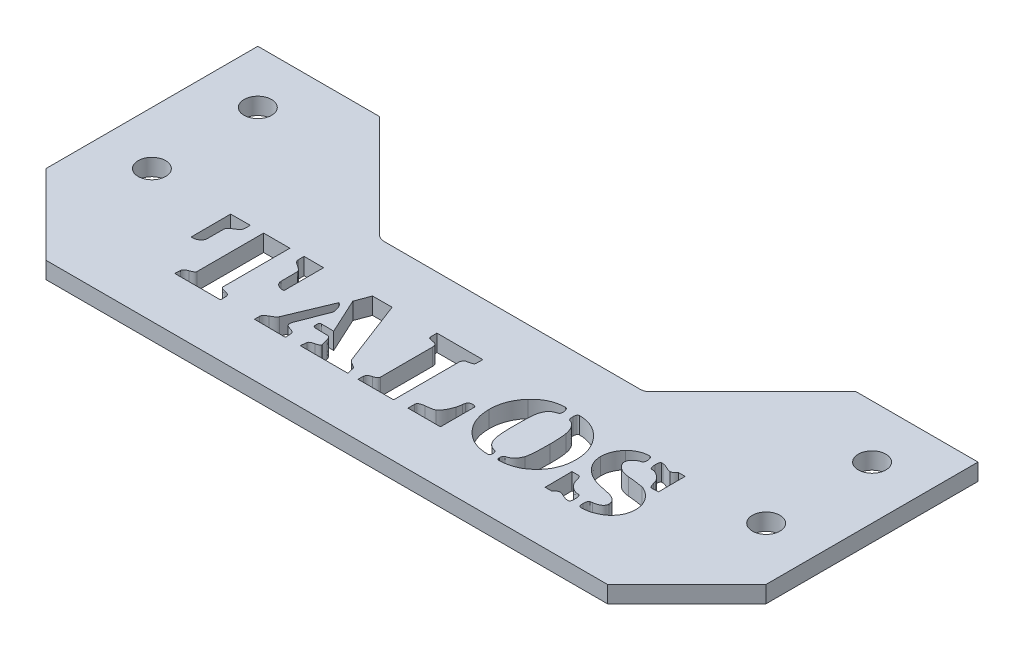
from build123d import *

# Parameters (mm, degrees)
SKETCH1_R           = 2.6
BOSS_EXTRUDE1_DEPTH = 3.175
BOSS_EXTRUDE2_DEPTH = 3.175
CUT_EXTRUDE1_DEPTH  = 3.175
BOSS_EXTRUDE3_DEPTH = 3.175


with BuildPart() as part:
    # Sketch1 → Boss-Extrude1 (new body)
    with BuildSketch(Plane(origin=(0, 0, 0), x_dir=(1, 0, 0), z_dir=(0, 1, 0))):
        Polygon((-48, 40), (-48, 30), (-38, 20), (38, 20), (48, 30), (48, 40), (68, 40), (68, 0), (-68, 0), (-68, 40), align=None)
        with Locations((-58, 10)):
            Circle(SKETCH1_R, mode=Mode.SUBTRACT)
        with Locations((-58, 30)):
            Circle(SKETCH1_R, mode=Mode.SUBTRACT)
        with Locations((58, 10)):
            Circle(SKETCH1_R, mode=Mode.SUBTRACT)
        with Locations((58, 30)):
            Circle(SKETCH1_R, mode=Mode.SUBTRACT)
    extrude(amount=BOSS_EXTRUDE1_DEPTH)

    # Sketch3 → Boss-Extrude2 (add)
    with BuildSketch(Plane(origin=(0, 3.175, 0), x_dir=(1, 0, 0), z_dir=(0, 1, 0))):
        Polygon((-68, 0), (-53, -15), (53, -15), (68, 0), align=None)
    extrude(amount=-BOSS_EXTRUDE2_DEPTH)

    # Sketch2 → Cut-Extrude1 (cut)
    with BuildSketch(Plane(origin=(0, 3.175, 0), x_dir=(1, 0, 0), z_dir=(0, 1, 0))):
        with BuildLine():
            Line((-25.572289157, 9.988704819), (-29.271460843, 10.008471386))
            Line((-29.271460843, 10.008471386), (-29.251694277, 8.895896084))
            add(Edge.make_bspline(
                [(-29.251694277, 8.895896084), (-29.244810481, 8.816288402), (-29.230633713, 8.652341114), (-29.101547691, 8.42473674), (-28.907964649, 8.211637037), (-28.73902133, 8.098705801), (-28.647402108, 8.037462349)],
                knots=[0, 0, 0, 0, 0.000237232, 0.000488566, 0.000766462, 0.001095734, 0.001095734, 0.001095734, 0.001095734], degree=3))
            add(Edge.make_bspline(
                [(-28.647402108, 8.037462349), (-28.5487272, 7.977475118), (-28.362782418, 7.864434096), (-28.112178036, 7.686962707), (-27.89493018, 7.527146053), (-27.717086255, 7.376724249), (-27.578675095, 7.235334449), (-27.480393852, 7.104093974), (-27.414282986, 6.9832808), (-27.403915935, 6.901929575), (-27.399284639, 6.865587349)],
                knots=[0, 0, 0, 0, 0.000346315, 0.000652603, 0.000920863, 0.00115517, 0.00135089, 0.001512415, 0.001647545, 0.001756654, 0.001756654, 0.001756654, 0.001756654], degree=3))
            Line((-27.399284639, 6.865587349), (-27.379518072, 3.782003012))
            add(Edge.make_bspline(
                [(-27.379518072, 3.782003012), (-27.374589184, 3.687691356), (-27.364928076, 3.502831179), (-27.256632142, 3.244988627), (-27.096764104, 3.008888952), (-26.944794445, 2.889688116), (-26.865587349, 2.827560241)],
                knots=[0, 0, 0, 0, 0.000281276, 0.000551329, 0.000827079, 0.001127253, 0.001127253, 0.001127253, 0.001127253], degree=3))
            add(Edge.make_bspline(
                [(-26.865587349, 2.827560241), (-26.783334512, 2.775611606), (-26.622990642, 2.674342819), (-26.359754741, 2.575024016), (-26.093758013, 2.504026506), (-25.911611807, 2.497571333), (-25.820783133, 2.49435241)],
                knots=[0, 0, 0, 0, 0.00029107, 0.000567413, 0.00084068, 0.001112484, 0.001112484, 0.001112484, 0.001112484], degree=3))
            add(Edge.make_bspline(
                [(-25.820783133, 2.49435241), (-25.767882589, 2.49425141), (-25.684405876, 2.494092034), (-25.602346264, 2.50875), (-25.572289157, 2.514118976)],
                knots=[0, 0, 0, 0, 0.000158233, 0.000249691, 0.000249691, 0.000249691, 0.000249691], degree=3))
            Line((-25.572289157, 2.514118976), (-25.572289157, 9.988704819))
        make_face()
        with BuildLine():
            Line((-39.420180723, 10.008471386), (-43.122176205, 9.988704819))
            Line((-43.122176205, 9.988704819), (-43.102409639, 2.514118976))
            add(Edge.make_bspline(
                [(-43.102409639, 2.514118976), (-43.074240986, 2.508739355), (-42.99972632, 2.494508621), (-42.923756871, 2.494412311), (-42.876506024, 2.49435241)],
                knots=[0, 0, 0, 0, 8.5882e-05, 0.000227185, 0.000227185, 0.000227185, 0.000227185], degree=3))
            add(Edge.make_bspline(
                [(-42.876506024, 2.49435241), (-42.78378989, 2.497472699), (-42.5997512, 2.503666379), (-42.333442928, 2.574091727), (-42.074717454, 2.673971504), (-41.919537471, 2.775589414), (-41.840173193, 2.827560241)],
                knots=[0, 0, 0, 0, 0.000277437, 0.000550704, 0.000821803, 0.001105591, 0.001105591, 0.001105591, 0.001105591], degree=3))
            add(Edge.make_bspline(
                [(-41.840173193, 2.827560241), (-41.760730213, 2.890102757), (-41.607523189, 3.010716974), (-41.435805277, 3.24155166), (-41.334307763, 3.504005986), (-41.32149825, 3.687937765), (-41.314947289, 3.782003012)],
                knots=[0, 0, 0, 0, 0.000302304, 0.000582999, 0.000852031, 0.001133633, 0.001133633, 0.001133633, 0.001133633], degree=3))
            Line((-41.314947289, 3.782003012), (-41.295180723, 6.865587349))
            add(Edge.make_bspline(
                [(-41.295180723, 6.865587349), (-41.292317785, 6.905463948), (-41.286436117, 6.987387094), (-41.240315004, 7.109820804), (-41.164219972, 7.230353632), (-41.06418233, 7.356717528), (-40.93323388, 7.482548362), (-40.773171628, 7.609092859), (-40.587149708, 7.739506596), (-40.449619656, 7.820095819), (-40.377447289, 7.862387048)],
                knots=[0, 0, 0, 0, 0.000119437, 0.000245373, 0.000387267, 0.000546029, 0.000727742, 0.000930603, 0.001157774, 0.001408631, 0.001408631, 0.001408631, 0.001408631], degree=3))
            add(Edge.make_bspline(
                [(-40.377447289, 7.862387048), (-40.303218502, 7.906341781), (-40.1621901, 7.989852047), (-39.974262571, 8.127380047), (-39.809024573, 8.255970068), (-39.677944257, 8.388052471), (-39.572121598, 8.516356399), (-39.498468653, 8.644157169), (-39.448219449, 8.769903463), (-39.442631728, 8.855009597), (-39.439947289, 8.895896084)],
                knots=[0, 0, 0, 0, 0.00025862, 0.000491356, 0.000698189, 0.000885881, 0.001048611, 0.001195367, 0.001327573, 0.001449815, 0.001449815, 0.001449815, 0.001449815], degree=3))
            Line((-39.439947289, 8.895896084), (-39.420180723, 10.008471386))
        make_face()
        with BuildLine():
            Line((-30.050828313, -5), (-30.07059488, -3.926957831))
            add(Edge.make_bspline(
                [(-30.07059488, -3.926957831), (-30.075971847, -3.878507937), (-30.086493795, -3.783698501), (-30.138791707, -3.650653945), (-30.22178558, -3.53455804), (-30.329822574, -3.432381486), (-30.466661918, -3.347259994), (-30.629135479, -3.276483174), (-30.819891858, -3.225013828), (-30.956123025, -3.200193639), (-31.027861446, -3.187123494)],
                knots=[0, 0, 0, 0, 0.000145775, 0.00028526, 0.000423135, 0.000570947, 0.000728397, 0.000904154, 0.001100809, 0.001319557, 0.001319557, 0.001319557, 0.001319557], degree=3))
            add(Edge.make_bspline(
                [(-31.027861446, -3.187123494), (-31.099556725, -3.171877191), (-31.234479808, -3.143185228), (-31.421562711, -3.091629594), (-31.578641357, -3.028072339), (-31.709324415, -2.962944087), (-31.812010585, -2.887832109), (-31.88771895, -2.806824155), (-31.934381978, -2.715141931), (-31.940004055, -2.6510734), (-31.942771084, -2.619540663)],
                knots=[0, 0, 0, 0, 0.000219912, 0.000413851, 0.000581124, 0.000727635, 0.000850754, 0.000960737, 0.001057984, 0.001152233, 0.001152233, 0.001152233, 0.001152233], degree=3))
            Line((-31.942771084, -2.619540663), (-31.942771084, 10))
            Line((-31.942771084, 10), (-36.901355422, 10))
            Line((-36.901355422, 10), (-36.901355422, -2.563064759))
            add(Edge.make_bspline(
                [(-36.901355422, -2.563064759), (-36.904431605, -2.592624526), (-36.910751029, -2.653349343), (-36.953709966, -2.742440166), (-37.028410641, -2.823142072), (-37.12478405, -2.905200966), (-37.248898436, -2.985297502), (-37.402098144, -3.058548341), (-37.580212477, -3.136428089), (-37.710447406, -3.180617462), (-37.779555723, -3.204066265)],
                knots=[0, 0, 0, 0, 8.8669e-05, 0.000182153, 0.000290272, 0.000416461, 0.000561358, 0.000731841, 0.00092539, 0.001144211, 0.001144211, 0.001144211, 0.001144211], degree=3))
            add(Edge.make_bspline(
                [(-37.779555723, -3.204066265), (-37.846776908, -3.227531772), (-37.974479062, -3.272109919), (-38.149545107, -3.35078448), (-38.300172184, -3.434979399), (-38.42189832, -3.530601489), (-38.517203827, -3.633700831), (-38.588243247, -3.742462966), (-38.629437778, -3.862017239), (-38.635118175, -3.944543032), (-38.637989458, -3.98625753)],
                knots=[0, 0, 0, 0, 0.00021351, 0.000405611, 0.000575132, 0.000729927, 0.000867831, 0.000994745, 0.001117084, 0.001242131, 0.001242131, 0.001242131, 0.001242131], degree=3))
            Line((-38.637989458, -3.98625753), (-38.67752259, -5))
            Line((-38.67752259, -5), (-30.050828313, -5))
        make_face()
        with BuildLine():
            Line((-6.02315512, -4.977409639), (-6.297063253, -3.749058735))
            add(Edge.make_bspline(
                [(-6.297063253, -3.749058735), (-6.317012268, -3.700327558), (-6.363432115, -3.586933796), (-6.519623867, -3.436030994), (-6.74216395, -3.277805804), (-6.920788405, -3.177733212), (-7.019954819, -3.122176205)],
                knots=[0, 0, 0, 0, 0.000156612, 0.000364425, 0.000637225, 0.000977689, 0.000977689, 0.000977689, 0.000977689], degree=3))
            add(Edge.make_bspline(
                [(-7.019954819, -3.122176205), (-7.126788487, -3.063203193), (-7.323391985, -2.954676539), (-7.574872076, -2.773961025), (-7.764637258, -2.59629852), (-7.843135342, -2.462290819), (-7.878388554, -2.402108434)],
                knots=[0, 0, 0, 0, 0.000365668, 0.00067293, 0.000928511, 0.00113686, 0.00113686, 0.00113686, 0.00113686], degree=3))
            Line((-7.878388554, -2.402108434), (-12.639307229, 10))
            Line((-12.639307229, 10), (-16.33000753, 9.980233434))
            Line((-16.33000753, 9.980233434), (-17.34375, 7.272213855))
            Line((-17.34375, 7.272213855), (-14.240399096, 0.565700301))
            Line((-14.240399096, 0.565700301), (-16.56438253, 0.602409639))
            add(Edge.make_bspline(
                [(-16.56438253, 0.602409639), (-16.594884586, 0.601491447), (-16.653936453, 0.59971383), (-16.734581583, 0.565541105), (-16.805806427, 0.517640562), (-16.859247554, 0.444755084), (-16.906483691, 0.357414357), (-16.930659558, 0.246498504), (-16.952689902, 0.119484872), (-16.953587554, 0.027438503), (-16.954066265, -0.021649096)],
                knots=[0, 0, 0, 0, 9.0758e-05, 0.000175707, 0.000258757, 0.000345194, 0.000443704, 0.000554662, 0.000683261, 0.000830207, 0.000830207, 0.000830207, 0.000830207], degree=3))
            add(Edge.make_bspline(
                [(-16.954066265, -0.021649096), (-16.953448835, -0.071629779), (-16.952289738, -0.165458106), (-16.93183991, -0.296079548), (-16.902497468, -0.408252754), (-16.857366514, -0.501407508), (-16.796837383, -0.573590769), (-16.724835783, -0.627254595), (-16.637848261, -0.655707511), (-16.576808909, -0.660253165), (-16.544615964, -0.662650602)],
                knots=[0, 0, 0, 0, 0.000149768, 0.000281158, 0.000395582, 0.000496609, 0.000588805, 0.000675795, 0.000762417, 0.000859088, 0.000859088, 0.000859088, 0.000859088], degree=3))
            add(Edge.make_bspline(
                [(-16.544615964, -0.662650602), (-16.368598212, -0.66232773), (-16.036326572, -0.661718237), (-15.567585216, -0.665727867), (-15.158109743, -0.667155851), (-14.807030692, -0.673503827), (-14.514302767, -0.679266009), (-14.279849571, -0.683615633), (-14.103800321, -0.691847497), (-14.006013982, -0.69920856), (-13.966490964, -0.702183735)],
                knots=[0, 0, 0, 0, 0.00052805, 0.000996808, 0.001406268, 0.001756464, 0.002050193, 0.002284636, 0.002459917, 0.002578818, 0.002578818, 0.002578818, 0.002578818], degree=3))
            add(Edge.make_bspline(
                [(-13.966490964, -0.702183735), (-13.909416024, -0.740873882), (-13.787568584, -0.823472223), (-13.646526601, -1.015765931), (-13.52739554, -1.258178887), (-13.471424264, -1.441871276), (-13.44126506, -1.540850904)],
                knots=[0, 0, 0, 0, 0.000205575, 0.000438876, 0.000704073, 0.001013932, 0.001013932, 0.001013932, 0.001013932], degree=3))
            Line((-13.44126506, -1.540850904), (-13.20689006, -2.537650602))
            add(Edge.make_bspline(
                [(-13.20689006, -2.537650602), (-13.184175183, -2.586683098), (-13.146456314, -2.668103319), (-13.13312628, -2.756592514), (-13.127823795, -2.791792169)],
                knots=[0, 0, 0, 0, 0.000160981, 0.000267315, 0.000267315, 0.000267315, 0.000267315], degree=3))
            add(Edge.make_bspline(
                [(-13.127823795, -2.791792169), (-13.131089114, -2.813024734), (-13.138128602, -2.858798627), (-13.183421197, -2.922999315), (-13.251652424, -2.984482146), (-13.349754591, -3.039719772), (-13.469560655, -3.099269818), (-13.61875981, -3.154386593), (-13.792713644, -3.211138556), (-13.919202883, -3.243425938), (-13.98625753, -3.260542169)],
                knots=[0, 0, 0, 0, 6.3708e-05, 0.000137343, 0.000229279, 0.000338243, 0.000473373, 0.000630696, 0.000814655, 0.001022199, 0.001022199, 0.001022199, 0.001022199], degree=3))
            add(Edge.make_bspline(
                [(-13.98625753, -3.260542169), (-14.055066617, -3.278962342), (-14.18396504, -3.313468414), (-14.364434788, -3.368183778), (-14.516022007, -3.431701792), (-14.645209744, -3.491049511), (-14.74571211, -3.558725226), (-14.818693907, -3.630266529), (-14.868684836, -3.70531243), (-14.879202736, -3.759768562), (-14.884224398, -3.785768072)],
                knots=[0, 0, 0, 0, 0.000213734, 0.000400382, 0.000565036, 0.00070648, 0.000826316, 0.000926153, 0.001012359, 0.001091123, 0.001091123, 0.001091123, 0.001091123], degree=3))
            Line((-14.884224398, -3.785768072), (-15.042356928, -4.957643072))
            Line((-15.042356928, -4.957643072), (-6.02315512, -4.977409639))
        make_face()
        with BuildLine():
            add(Edge.make_bspline(
                [(-19.647966867, -2.404932229), (-19.641873699, -2.297468451), (-19.629302892, -2.075760067), (-19.550306916, -1.868108279), (-19.509600904, -1.761106928)],
                knots=[0, 0, 0, 0, 0.000320883, 0.000662013, 0.000662013, 0.000662013, 0.000662013], degree=3))
            Line((-19.509600904, -1.761106928), (-17.482115964, 3.471385542))
            add(Edge.make_bspline(
                [(-17.482115964, 3.471385542), (-17.464471768, 3.511251919), (-17.428650773, 3.59218807), (-17.424780284, 3.680642369), (-17.422816265, 3.725527108)],
                knots=[0, 0, 0, 0, 0.000129557, 0.000263024, 0.000263024, 0.000263024, 0.000263024], degree=3))
            add(Edge.make_bspline(
                [(-17.422816265, 3.725527108), (-17.431340152, 3.86271766), (-17.449188976, 4.149991553), (-17.573657571, 4.587584293), (-17.770580664, 5.046667008), (-17.95156563, 5.344729922), (-18.046875, 5.501694277)],
                knots=[0, 0, 0, 0, 0.000411354, 0.000861367, 0.001355991, 0.001906232, 0.001906232, 0.001906232, 0.001906232], degree=3))
            add(Edge.make_bspline(
                [(-18.046875, 5.501694277), (-18.079102423, 5.516291272), (-18.142818433, 5.545150616), (-18.235373801, 5.59710933), (-18.323827292, 5.65812014), (-18.38558048, 5.696768707), (-18.416792169, 5.716302711)],
                knots=[0, 0, 0, 0, 0.000106109, 0.000209785, 0.000317866, 0.00042832, 0.00042832, 0.00042832, 0.00042832], degree=3))
            Line((-18.416792169, 5.716302711), (-21.71498494, -2.150790663))
            add(Edge.make_bspline(
                [(-21.71498494, -2.150790663), (-21.732817154, -2.187138394), (-21.770586389, -2.264124124), (-21.85235488, -2.37475643), (-21.956957548, -2.486903914), (-22.085895541, -2.59960132), (-22.236455408, -2.716030532), (-22.41112659, -2.833575716), (-22.610327072, -2.952683225), (-22.752847982, -3.028683342), (-22.827560241, -3.068524096)],
                knots=[0, 0, 0, 0, 0.000121259, 0.00025683, 0.000410695, 0.00058071, 0.000769925, 0.00098139, 0.001211905, 0.00146589, 0.00146589, 0.00146589, 0.00146589], degree=3))
            add(Edge.make_bspline(
                [(-22.827560241, -3.068524096), (-22.893982788, -3.104312834), (-23.01972403, -3.172062724), (-23.192108955, -3.283605794), (-23.338118213, -3.396663145), (-23.457181437, -3.515541754), (-23.552024579, -3.63564368), (-23.617867451, -3.762263286), (-23.660213482, -3.891349376), (-23.666123363, -3.979363425), (-23.669051205, -4.022966867)],
                knots=[0, 0, 0, 0, 0.000226274, 0.000428348, 0.000615338, 0.000779069, 0.000932128, 0.001072326, 0.001205405, 0.001336064, 0.001336064, 0.001336064, 0.001336064], degree=3))
            Line((-23.669051205, -4.022966867), (-23.669051205, -4.960466867))
            Line((-23.669051205, -4.960466867), (-17.792733434, -5))
            Line((-17.792733434, -5), (-17.871799699, -3.768825301))
            add(Edge.make_bspline(
                [(-17.871799699, -3.768825301), (-17.87565177, -3.738205693), (-17.883631339, -3.67477716), (-17.932682076, -3.584854548), (-18.010217202, -3.503120026), (-18.108868131, -3.420960445), (-18.235536004, -3.344474196), (-18.390483775, -3.275968351), (-18.569508728, -3.20415987), (-18.77028784, -3.145462046), (-18.969148146, -3.082407064), (-19.149032776, -3.008806879), (-19.302467604, -2.929304441), (-19.425974379, -2.837207169), (-19.523656529, -2.740743334), (-19.598370234, -2.638522962), (-19.639289682, -2.523586427), (-19.645054738, -2.444753479), (-19.647966867, -2.404932229)],
                knots=[0, 0, 0, 0, 9.1936e-05, 0.000190446, 0.000300429, 0.00042878, 0.000574554, 0.000742588, 0.000936609, 0.001152736, 0.001369728, 0.001562181, 0.001735264, 0.00188662, 0.002022398, 0.002146162, 0.002263171, 0.002382608, 0.002382608, 0.002382608, 0.002382608], degree=3))
        make_face()
        with BuildLine():
            Line((11.484375, -5), (11.484375, 1.32247741))
            add(Edge.make_bspline(
                [(11.484375, 1.32247741), (11.483218477, 1.354719406), (11.481022546, 1.415938425), (11.451357637, 1.501925201), (11.401451607, 1.573591993), (11.33449168, 1.63618773), (11.245581683, 1.679013076), (11.139797497, 1.710476047), (11.016321723, 1.729860641), (10.92721853, 1.73121255), (10.880082831, 1.731927711)],
                knots=[0, 0, 0, 0, 9.6382e-05, 0.000183004, 0.000268374, 0.000356321, 0.00045483, 0.000561127, 0.000686936, 0.000828239, 0.000828239, 0.000828239, 0.000828239], degree=3))
            add(Edge.make_bspline(
                [(10.880082831, 1.731927711), (10.824455492, 1.730387108), (10.717279307, 1.727418856), (10.565127571, 1.702680006), (10.429054747, 1.659754068), (10.309382258, 1.600631893), (10.204267575, 1.523555671), (10.120912436, 1.424852392), (10.046654924, 1.314727042), (10.01702976, 1.230169289), (10.00188253, 1.186935241)],
                knots=[0, 0, 0, 0, 0.000166819, 0.000321407, 0.000460721, 0.000593319, 0.00072039, 0.00084843, 0.000979242, 0.001116101, 0.001116101, 0.001116101, 0.001116101], degree=3))
            add(Edge.make_bspline(
                [(10.00188253, 1.186935241), (9.990995393, 1.13809868), (9.970577368, 1.046509295), (9.950263263, 0.919142309), (9.94284425, 0.810629646), (9.929117089, 0.747268343), (9.922816265, 0.718185241)],
                knots=[0, 0, 0, 0, 0.000150087, 0.000281477, 0.000386566, 0.000475728, 0.000475728, 0.000475728, 0.000475728], degree=3))
            add(Edge.make_bspline(
                [(9.922816265, 0.718185241), (9.909031184, 0.613493555), (9.883096331, 0.416529656), (9.827283581, 0.141221397), (9.772324265, -0.100334651), (9.728658395, -0.248674023), (9.708207831, -0.31814759)],
                knots=[0, 0, 0, 0, 0.000316681, 0.000595794, 0.000842371, 0.001059583, 0.001059583, 0.001059583, 0.001059583], degree=3))
            add(Edge.make_bspline(
                [(9.708207831, -0.31814759), (9.668436748, -0.448590754), (9.590677615, -0.703628996), (9.449641413, -1.066727909), (9.293049432, -1.401983309), (9.126086024, -1.711082915), (8.937159133, -1.988876091), (8.737419224, -2.242054095), (8.520118813, -2.46696635), (8.360731029, -2.595659224), (8.282191265, -2.659073795)],
                knots=[0, 0, 0, 0, 0.000409012, 0.000799687, 0.001167312, 0.001518656, 0.001852294, 0.002173786, 0.0024853, 0.002787921, 0.002787921, 0.002787921, 0.002787921], degree=3))
            add(Edge.make_bspline(
                [(8.282191265, -2.659073795), (8.253610623, -2.678135189), (8.187951557, -2.721925434), (8.059310634, -2.764983), (7.898971856, -2.814042826), (7.699569118, -2.858161453), (7.463668379, -2.89839669), (7.191168576, -2.942948349), (6.880799991, -2.976874895), (6.661336055, -2.999900807), (6.545557229, -3.012048193)],
                knots=[0, 0, 0, 0, 0.000102671, 0.000235869, 0.000403832, 0.000606595, 0.000847546, 0.00112192, 0.001434699, 0.00178396, 0.00178396, 0.00178396, 0.00178396], degree=3))
            add(Edge.make_bspline(
                [(6.545557229, -3.012048193), (6.452160127, -3.023830334), (6.276492275, -3.045991016), (6.032789224, -3.097946933), (5.826185924, -3.167587023), (5.655909038, -3.255403581), (5.52050436, -3.358957603), (5.421633991, -3.481004407), (5.366102832, -3.622365352), (5.358025112, -3.721311398), (5.353915663, -3.771649096)],
                knots=[0, 0, 0, 0, 0.000282337, 0.00053104, 0.00074626, 0.000934461, 0.001103371, 0.001254199, 0.001399974, 0.001550935, 0.001550935, 0.001550935, 0.001550935], degree=3))
            Line((5.353915663, -3.771649096), (5.353915663, -5))
            Line((5.353915663, -5), (11.484375, -5))
        make_face()
        with BuildLine():
            Line((2.643072289, -5), (2.643072289, 7.229856928))
            add(Edge.make_bspline(
                [(2.643072289, 7.229856928), (2.647120539, 7.324982126), (2.654827324, 7.50607507), (2.750750418, 7.753371716), (2.898603973, 7.964923665), (3.03933207, 8.059394508), (3.111822289, 8.108057229)],
                knots=[0, 0, 0, 0, 0.000283788, 0.000540256, 0.00078482, 0.001044625, 0.001044625, 0.001044625, 0.001044625], degree=3))
            add(Edge.make_bspline(
                [(3.111822289, 8.108057229), (3.122157262, 8.111869142), (3.150085414, 8.122170058), (3.203213347, 8.139554691), (3.280556651, 8.154110373), (3.379973433, 8.178160362), (3.502613892, 8.205235372), (3.646555397, 8.239439131), (3.811197956, 8.279302533), (3.927900032, 8.307601583), (3.99002259, 8.322665663)],
                knots=[0, 0, 0, 0, 3.3052e-05, 8.9315e-05, 0.000167418, 0.000268799, 0.000396215, 0.000544161, 0.000712645, 0.000904414, 0.000904414, 0.000904414, 0.000904414], degree=3))
            add(Edge.make_bspline(
                [(3.99002259, 8.322665663), (4.060164994, 8.342810601), (4.187547159, 8.379394833), (4.343941213, 8.476204521), (4.45153495, 8.601848823), (4.467694982, 8.702117983), (4.475715361, 8.75188253)],
                knots=[0, 0, 0, 0, 0.00021789, 0.0003957, 0.000546528, 0.000695147, 0.000695147, 0.000695147, 0.000695147], degree=3))
            Line((4.475715361, 8.75188253), (4.495481928, 10))
            Line((4.495481928, 10), (-4.170745482, 10))
            Line((-4.170745482, 10), (-4.150978916, 8.791415663))
            add(Edge.make_bspline(
                [(-4.150978916, 8.791415663), (-4.146677669, 8.734300641), (-4.138289511, 8.622916716), (-4.036860711, 8.480972085), (-3.879245808, 8.382690901), (-3.752527992, 8.356797228), (-3.682228916, 8.342432229)],
                knots=[0, 0, 0, 0, 0.00016898, 0.00032954, 0.000501072, 0.000714806, 0.000714806, 0.000714806, 0.000714806], degree=3))
            add(Edge.make_bspline(
                [(-3.682228916, 8.342432229), (-3.613543325, 8.330037097), (-3.484703657, 8.306786445), (-3.304597989, 8.276691779), (-3.151978827, 8.248902199), (-3.027231354, 8.222495897), (-2.928196624, 8.202954672), (-2.85595109, 8.18848353), (-2.809120502, 8.180796137), (-2.789837511, 8.170371187), (-2.784262048, 8.167356928)],
                knots=[0, 0, 0, 0, 0.00020938, 0.000392753, 0.000547831, 0.00067465, 0.00077544, 0.000850204, 0.000896775, 0.000915718, 0.000915718, 0.000915718, 0.000915718], degree=3))
            add(Edge.make_bspline(
                [(-2.784262048, 8.167356928), (-2.711997833, 8.127627269), (-2.570450009, 8.049806638), (-2.416784462, 7.851775227), (-2.328130594, 7.60502523), (-2.319890146, 7.424566391), (-2.315512048, 7.328689759)],
                knots=[0, 0, 0, 0, 0.000245167, 0.000480221, 0.000733057, 0.001019655, 0.001019655, 0.001019655, 0.001019655], degree=3))
            Line((-2.315512048, 7.328689759), (-2.315512048, -2.563064759))
            add(Edge.make_bspline(
                [(-2.315512048, -2.563064759), (-2.318546619, -2.593581674), (-2.324768146, -2.656147965), (-2.367867253, -2.747021801), (-2.438352183, -2.831585345), (-2.533651284, -2.914540791), (-2.656479952, -2.99185566), (-2.804067869, -3.069154815), (-2.980529875, -3.137375301), (-3.106976073, -3.180974708), (-3.173945783, -3.204066265)],
                knots=[0, 0, 0, 0, 9.1458e-05, 0.000187508, 0.000295995, 0.000420049, 0.000564946, 0.000730397, 0.00091917, 0.001131725, 0.001131725, 0.001131725, 0.001131725], degree=3))
            add(Edge.make_bspline(
                [(-3.173945783, -3.204066265), (-3.241212193, -3.22345006), (-3.3693203, -3.260366277), (-3.545747799, -3.333769627), (-3.696231563, -3.418563503), (-3.82229047, -3.510798911), (-3.921901893, -3.614516586), (-3.992947915, -3.729101434), (-4.041974979, -3.853586091), (-4.048719529, -3.941561695), (-4.052146084, -3.98625753)],
                knots=[0, 0, 0, 0, 0.000209894, 0.00039974, 0.000571714, 0.000727022, 0.00086685, 0.001000048, 0.001129605, 0.0012634, 0.0012634, 0.0012634, 0.0012634], degree=3))
            Line((-4.052146084, -3.98625753), (-4.091679217, -5))
            Line((-4.091679217, -5), (2.643072289, -5))
        make_face()
        with BuildLine():
            add(Edge.make_bspline(
                [(29.672439759, 2.435052711), (29.666935647, 2.686703897), (29.656071517, 3.183418194), (29.555838974, 3.914693996), (29.400202443, 4.620788894), (29.173812871, 5.29967524), (28.889289696, 5.953863936), (28.537787899, 6.581472392), (28.127424644, 7.186801731), (27.80511021, 7.558607054), (27.642131024, 7.746611446)],
                knots=[0, 0, 0, 0, 0.000754593, 0.001489431, 0.002210119, 0.002920919, 0.00363284, 0.004347043, 0.005076244, 0.005822121, 0.005822121, 0.005822121, 0.005822121], degree=3))
            add(Edge.make_bspline(
                [(27.642131024, 7.746611446), (27.472390256, 7.924361154), (27.139561345, 8.272894052), (26.590558911, 8.724931619), (26.019895024, 9.109966469), (25.424274889, 9.426292705), (24.802169878, 9.669498427), (24.156980693, 9.845822617), (23.487241221, 9.953383532), (23.032210069, 9.9655903), (22.802146084, 9.971762048)],
                knots=[0, 0, 0, 0, 0.000736794, 0.001444711, 0.002128431, 0.00279917, 0.003463555, 0.004128035, 0.004802591, 0.00549243, 0.00549243, 0.00549243, 0.00549243], degree=3))
            add(Edge.make_bspline(
                [(22.802146084, 9.971762048), (22.765120064, 9.969996841), (22.693716246, 9.966592681), (22.59387958, 9.928763828), (22.512251025, 9.863141694), (22.446133802, 9.774291214), (22.392125386, 9.662680175), (22.357061044, 9.525568969), (22.338968538, 9.36513514), (22.335339521, 9.250800212), (22.333396084, 9.189570783)],
                knots=[0, 0, 0, 0, 0.000110706, 0.000213493, 0.000314046, 0.000420791, 0.000543293, 0.000683719, 0.000843082, 0.001026824, 0.001026824, 0.001026824, 0.001026824], degree=3))
            add(Edge.make_bspline(
                [(22.333396084, 9.189570783), (22.33366023, 9.115099991), (22.334156557, 8.975170343), (22.358946168, 8.780152931), (22.388011904, 8.612647136), (22.440501259, 8.47717656), (22.501747761, 8.368765429), (22.57968842, 8.287567423), (22.677054705, 8.23954198), (22.747062494, 8.23473115), (22.782379518, 8.232304217)],
                knots=[0, 0, 0, 0, 0.000223151, 0.000419298, 0.000589313, 0.000731432, 0.000852986, 0.00096081, 0.00106437, 0.0011698, 0.0011698, 0.0011698, 0.0011698], degree=3))
            add(Edge.make_bspline(
                [(22.782379518, 8.232304217), (22.886647253, 8.183586536), (23.09446325, 8.086487337), (23.377940911, 7.885143675), (23.628665293, 7.6341639), (23.851812388, 7.339553436), (24.044358119, 6.997603077), (24.210671016, 6.612738905), (24.345970663, 6.180807293), (24.409681728, 5.875084639), (24.442771084, 5.716302711)],
                knots=[0, 0, 0, 0, 0.000344758, 0.000687136, 0.001036569, 0.001405363, 0.001792388, 0.002211006, 0.002661115, 0.003147497, 0.003147497, 0.003147497, 0.003147497], degree=3))
            add(Edge.make_bspline(
                [(24.442771084, 5.716302711), (24.458627556, 5.634545704), (24.49311677, 5.456717059), (24.530719378, 5.165284245), (24.563783892, 4.830963111), (24.593019112, 4.452548563), (24.609870398, 4.030551256), (24.62896917, 3.563781464), (24.635797006, 3.053482489), (24.636991815, 2.698606056), (24.637612952, 2.514118976)],
                knots=[0, 0, 0, 0, 0.00024979, 0.000543316, 0.000881051, 0.001257676, 0.001681706, 0.002147941, 0.002659118, 0.003212589, 0.003212589, 0.003212589, 0.003212589], degree=3))
            add(Edge.make_bspline(
                [(24.637612952, 2.514118976), (24.636329912, 2.238324096), (24.633881885, 1.712110487), (24.621070573, 0.962723646), (24.595625529, 0.29243944), (24.56217456, -0.29879476), (24.522357339, -0.81146282), (24.469356832, -1.244883621), (24.40891973, -1.59963394), (24.350123309, -1.805696847), (24.324171687, -1.896649096)],
                knots=[0, 0, 0, 0, 0.000827391, 0.001578653, 0.002248375, 0.00283952, 0.003355194, 0.003790553, 0.004149453, 0.00443303, 0.00443303, 0.00443303, 0.00443303], degree=3))
            add(Edge.make_bspline(
                [(24.324171687, -1.896649096), (24.279570769, -2.018148691), (24.193019749, -2.253926663), (24.026190838, -2.581083152), (23.829842521, -2.868870726), (23.608194776, -3.119724754), (23.360978763, -3.335213845), (23.082815671, -3.507851557), (22.779461411, -3.646428686), (22.562247387, -3.703266594), (22.451995482, -3.732115964)],
                knots=[0, 0, 0, 0, 0.000388043, 0.000753024, 0.001098428, 0.001430485, 0.001754841, 0.002078409, 0.002409564, 0.002750905, 0.002750905, 0.002750905, 0.002750905], degree=3))
            add(Edge.make_bspline(
                [(22.451995482, -3.732115964), (22.396967393, -3.756011574), (22.285547161, -3.804395126), (22.1727652, -3.965311469), (22.108733135, -4.173322575), (22.102481543, -4.329194322), (22.099021084, -4.415474398)],
                knots=[0, 0, 0, 0, 0.00017691, 0.000358206, 0.000566268, 0.000824224, 0.000824224, 0.000824224, 0.000824224], degree=3))
            add(Edge.make_bspline(
                [(22.099021084, -4.415474398), (22.100030159, -4.457866576), (22.10192318, -4.537394232), (22.117738635, -4.650023347), (22.148883854, -4.744672718), (22.187607548, -4.8256214), (22.242870424, -4.885263184), (22.307681732, -4.930846336), (22.386245066, -4.956111215), (22.44241321, -4.958972038), (22.471762048, -4.960466867)],
                knots=[0, 0, 0, 0, 0.000127196, 0.00023862, 0.000339529, 0.000425411, 0.00050538, 0.000580569, 0.000660936, 0.000748882, 0.000748882, 0.000748882, 0.000748882], degree=3))
            add(Edge.make_bspline(
                [(22.471762048, -4.960466867), (22.715901286, -4.953962647), (23.197739385, -4.941125788), (23.905979091, -4.83909672), (24.588079409, -4.677313116), (25.240169065, -4.441781839), (25.869400215, -4.149550773), (26.465225952, -3.780841516), (27.037032676, -3.352894517), (27.571854178, -2.860607898), (28.062230898, -2.320645232), (28.496424503, -1.742306391), (28.857845278, -1.126226335), (29.156581808, -0.47858426), (29.389709522, 0.202469861), (29.551353591, 0.917293378), (29.653550513, 1.664974384), (29.666059103, 2.174925584), (29.672439759, 2.435052711)],
                knots=[0, 0, 0, 0, 0.000732148, 0.001444981, 0.002142201, 0.002831716, 0.003521422, 0.004219773, 0.004929676, 0.005661175, 0.006396848, 0.007115225, 0.007826648, 0.008535466, 0.009251641, 0.009981842, 0.010731048, 0.011511152, 0.011511152, 0.011511152, 0.011511152], degree=3))
        make_face()
        with BuildLine():
            add(Edge.make_bspline(
                [(20.811370482, -4.316641566), (20.808546528, -4.23803023), (20.803357778, -4.093589277), (20.740970799, -3.96360733), (20.712537651, -3.90436747)],
                knots=[0, 0, 0, 0, 0.000232942, 0.000428009, 0.000428009, 0.000428009, 0.000428009], degree=3))
            add(Edge.make_bspline(
                [(20.712537651, -3.90436747), (20.662144432, -3.864524664), (20.577272965, -3.797422038), (20.480689466, -3.748973812), (20.441453313, -3.729292169)],
                knots=[0, 0, 0, 0, 0.000192039, 0.000323429, 0.000323429, 0.000323429, 0.000323429], degree=3))
            add(Edge.make_bspline(
                [(20.441453313, -3.729292169), (20.354294955, -3.70761018), (20.182924028, -3.664979013), (19.939013126, -3.570164146), (19.710627449, -3.454751519), (19.501103985, -3.312118726), (19.307936231, -3.147375264), (19.132024412, -2.960452131), (18.974753057, -2.748497063), (18.885894213, -2.59415018), (18.840361446, -2.515060241)],
                knots=[0, 0, 0, 0, 0.00026921, 0.000529321, 0.000783165, 0.001035353, 0.001287732, 0.001543437, 0.001803794, 0.002077411, 0.002077411, 0.002077411, 0.002077411], degree=3))
            add(Edge.make_bspline(
                [(18.840361446, -2.515060241), (18.794035522, -2.419932113), (18.695010694, -2.216589239), (18.582037647, -1.871021083), (18.488734648, -1.470854167), (18.406674585, -1.01677113), (18.345697867, -0.506651445), (18.306349726, 0.058827553), (18.276022875, 0.679271188), (18.273889138, 1.11159135), (18.272778614, 1.336596386)],
                knots=[0, 0, 0, 0, 0.000317134, 0.000677895, 0.001087462, 0.001549409, 0.002061475, 0.00262782, 0.003249696, 0.003924637, 0.003924637, 0.003924637, 0.003924637], degree=3))
            Line((18.272778614, 1.336596386), (18.272778614, 3.564570783))
            add(Edge.make_bspline(
                [(18.272778614, 3.564570783), (18.27269209, 3.725545632), (18.272525075, 4.036270278), (18.288928397, 4.486171551), (18.306359468, 4.902472821), (18.33626605, 5.285467324), (18.367228973, 5.636324983), (18.413807749, 5.953314172), (18.462316886, 6.238526172), (18.506155031, 6.414933681), (18.526920181, 6.498493976)],
                knots=[0, 0, 0, 0, 0.000482877, 0.000932083, 0.001350471, 0.001732728, 0.002084515, 0.002406786, 0.002693704, 0.002951923, 0.002951923, 0.002951923, 0.002951923], degree=3))
            add(Edge.make_bspline(
                [(18.526920181, 6.498493976), (18.572635764, 6.634431202), (18.659869995, 6.89382589), (18.834592806, 7.2429261), (19.020951628, 7.546627309), (19.175456556, 7.710233309), (19.249811747, 7.788968373)],
                knots=[0, 0, 0, 0, 0.000429672, 0.000819897, 0.001169239, 0.001493324, 0.001493324, 0.001493324, 0.001493324], degree=3))
            add(Edge.make_bspline(
                [(19.249811747, 7.788968373), (19.295743851, 7.830889631), (19.39210377, 7.918835284), (19.566725818, 8.026849313), (19.768812103, 8.123220476), (19.915647566, 8.174443357), (19.99246988, 8.20124247)],
                knots=[0, 0, 0, 0, 0.000186221, 0.000390668, 0.00061296, 0.000856871, 0.000856871, 0.000856871, 0.000856871], degree=3))
            add(Edge.make_bspline(
                [(19.99246988, 8.20124247), (20.057809153, 8.222879818), (20.176467723, 8.262174054), (20.332267669, 8.328309901), (20.453588614, 8.385152848), (20.512692587, 8.434643219), (20.537462349, 8.455384036)],
                knots=[0, 0, 0, 0, 0.000206292, 0.000374633, 0.000508518, 0.000605107, 0.000605107, 0.000605107, 0.000605107], degree=3))
            add(Edge.make_bspline(
                [(20.537462349, 8.455384036), (20.558280501, 8.490610621), (20.60109814, 8.563062737), (20.647338202, 8.68751631), (20.671301975, 8.830015179), (20.67427068, 8.930638326), (20.675828313, 8.983433735)],
                knots=[0, 0, 0, 0, 0.0001226, 0.000252156, 0.000395615, 0.000553974, 0.000553974, 0.000553974, 0.000553974], degree=3))
            add(Edge.make_bspline(
                [(20.675828313, 8.983433735), (20.671081661, 9.09781465), (20.661841686, 9.32047197), (20.578157348, 9.526883045), (20.537462349, 9.627259036)],
                knots=[0, 0, 0, 0, 0.000340545, 0.000662916, 0.000662916, 0.000662916, 0.000662916], degree=3))
            add(Edge.make_bspline(
                [(20.537462349, 9.627259036), (20.514201415, 9.683669395), (20.471234539, 9.787868859), (20.365384666, 9.909258583), (20.236041007, 9.989651152), (20.13857804, 9.99648644), (20.088478916, 10)],
                knots=[0, 0, 0, 0, 0.000181866, 0.000335938, 0.000476392, 0.000624957, 0.000624957, 0.000624957, 0.000624957], degree=3))
            add(Edge.make_bspline(
                [(20.088478916, 10), (19.856528303, 9.993880933), (19.398674845, 9.981802344), (18.725238507, 9.8739434), (18.0787803, 9.69864483), (17.456340189, 9.454452197), (16.863341398, 9.134518947), (16.290979916, 8.75247608), (15.749127586, 8.294058264), (15.417628369, 7.946519663), (15.248493976, 7.769201807)],
                knots=[0, 0, 0, 0, 0.00069548, 0.001372826, 0.002040031, 0.002701787, 0.003373851, 0.004057571, 0.004762966, 0.005497771, 0.005497771, 0.005497771, 0.005497771], degree=3))
            add(Edge.make_bspline(
                [(15.248493976, 7.769201807), (15.085811676, 7.580041819), (14.7650524, 7.207076715), (14.350969051, 6.603356785), (14.002350926, 5.973999213), (13.716009325, 5.318810223), (13.490998449, 4.638468698), (13.334681237, 3.931674237), (13.234580722, 3.200351225), (13.223698513, 2.703643393), (13.218185241, 2.451995482)],
                knots=[0, 0, 0, 0, 0.00074805, 0.001474924, 0.002191595, 0.002903516, 0.003616998, 0.004337686, 0.005072524, 0.005827117, 0.005827117, 0.005827117, 0.005827117], degree=3))
            add(Edge.make_bspline(
                [(13.218185241, 2.451995482), (13.223780829, 2.196607896), (13.234806587, 1.693382504), (13.333017963, 0.954876841), (13.4938835, 0.246539677), (13.720094532, -0.429773356), (14.009883054, -1.074760291), (14.362757828, -1.689041194), (14.779639506, -2.273314695), (15.104478375, -2.629266022), (15.268260542, -2.80873494)],
                knots=[0, 0, 0, 0, 0.000765879, 0.001509116, 0.002230429, 0.00294212, 0.00364486, 0.004348161, 0.005064426, 0.005792811, 0.005792811, 0.005792811, 0.005792811], degree=3))
            add(Edge.make_bspline(
                [(15.268260542, -2.80873494), (15.442552918, -2.984029886), (15.785742743, -3.329193819), (16.357845776, -3.773066385), (16.957113135, -4.155837309), (17.593284977, -4.462691562), (18.258501743, -4.70679693), (18.958166634, -4.873010738), (19.688759086, -4.982405412), (20.18784653, -4.99407182), (20.441453313, -5)],
                knots=[0, 0, 0, 0, 0.000740917, 0.0014589, 0.002167104, 0.002870546, 0.003573558, 0.004288575, 0.005024568, 0.005784924, 0.005784924, 0.005784924, 0.005784924], degree=3))
            add(Edge.make_bspline(
                [(20.441453313, -5), (20.470997258, -4.997958148), (20.527225166, -4.994072104), (20.605700079, -4.960121531), (20.672804481, -4.905359439), (20.722121631, -4.824651686), (20.765748528, -4.728529708), (20.79200768, -4.609557691), (20.808826681, -4.470577025), (20.81048276, -4.370361148), (20.811370482, -4.316641566)],
                knots=[0, 0, 0, 0, 8.8263e-05, 0.000167982, 0.000252224, 0.000343856, 0.000448794, 0.000567963, 0.000707363, 0.000868418, 0.000868418, 0.000868418, 0.000868418], degree=3))
        make_face()
        with BuildLine():
            Line((42.690135542, 10), (41.458960843, 10))
            add(Edge.make_bspline(
                [(41.458960843, 10), (41.383339384, 9.905350242), (41.242277558, 9.728793644), (40.992785609, 9.529199608), (40.73330548, 9.400511056), (40.552872892, 9.38398906), (40.46498494, 9.375941265)],
                knots=[0, 0, 0, 0, 0.000362338, 0.000675894, 0.000952597, 0.001215377, 0.001215377, 0.001215377, 0.001215377], degree=3))
            add(Edge.make_bspline(
                [(40.46498494, 9.375941265), (40.40534491, 9.380606111), (40.270611337, 9.391144526), (40.052374733, 9.458535715), (39.791618499, 9.553956378), (39.506256937, 9.686319012), (39.219599099, 9.824597544), (38.947196071, 9.918579056), (38.710852144, 9.98601482), (38.562100511, 9.995607011), (38.493975904, 10)],
                knots=[0, 0, 0, 0, 0.000178994, 0.000404367, 0.00068133, 0.001012485, 0.001347376, 0.00163496, 0.00187672, 0.002080992, 0.002080992, 0.002080992, 0.002080992], degree=3))
            Line((38.493975904, 10), (38.220067771, 10))
            add(Edge.make_bspline(
                [(38.220067771, 10), (38.199387011, 9.990960014), (38.155874268, 9.971939699), (38.104219524, 9.911889831), (38.059210794, 9.832824798), (38.027556399, 9.727364669), (37.998739052, 9.600213998), (37.981389986, 9.446849978), (37.965536353, 9.269900831), (37.965791309, 9.143497913), (37.965926205, 9.076618976)],
                knots=[0, 0, 0, 0, 6.6942e-05, 0.000140848, 0.000231913, 0.000339068, 0.000469239, 0.000623, 0.000801458, 0.001001967, 0.001001967, 0.001001967, 0.001001967], degree=3))
            add(Edge.make_bspline(
                [(37.965926205, 9.076618976), (37.96611845, 8.993675258), (37.966479771, 8.837783971), (37.99203553, 8.621438064), (38.018107061, 8.435351263), (38.067152597, 8.285114767), (38.123685188, 8.16294105), (38.202494952, 8.079767615), (38.292209964, 8.02033852), (38.360351949, 8.014850302), (38.395143072, 8.012048193)],
                knots=[0, 0, 0, 0, 0.000248558, 0.000467161, 0.000653317, 0.000810489, 0.000940567, 0.001052455, 0.001151248, 0.001254307, 0.001254307, 0.001254307, 0.001254307], degree=3))
            add(Edge.make_bspline(
                [(38.395143072, 8.012048193), (38.489700444, 8.008810559), (38.67920957, 8.002321787), (38.959628685, 7.931011997), (39.237896366, 7.828079812), (39.511351801, 7.676709555), (39.782913168, 7.487545838), (40.048600637, 7.252555374), (40.312440436, 6.977906661), (40.476080355, 6.771963097), (40.560993976, 6.665097892)],
                knots=[0, 0, 0, 0, 0.000283071, 0.000567322, 0.00086312, 0.001171419, 0.001501996, 0.001854235, 0.002233697, 0.002642982, 0.002642982, 0.002642982, 0.002642982], degree=3))
            add(Edge.make_bspline(
                [(40.560993976, 6.665097892), (40.568894072, 6.654971279), (40.58848308, 6.629861422), (40.612430719, 6.574887767), (40.646420165, 6.501519016), (40.683038713, 6.404269015), (40.720372868, 6.285245865), (40.771427701, 6.14662184), (40.819535146, 5.983516439), (40.855458207, 5.867795776), (40.874435241, 5.806664157)],
                knots=[0, 0, 0, 0, 3.8408e-05, 9.5236e-05, 0.000178669, 0.000281457, 0.000406471, 0.000552928, 0.000724414, 0.000916453, 0.000916453, 0.000916453, 0.000916453], degree=3))
            add(Edge.make_bspline(
                [(40.874435241, 5.806664157), (40.905675741, 5.701137282), (40.963038969, 5.507370784), (41.079407272, 5.253955053), (41.193030774, 5.048162866), (41.29659522, 4.951970755), (41.343185241, 4.908697289)],
                knots=[0, 0, 0, 0, 0.000329514, 0.000605048, 0.000837029, 0.001026728, 0.001026728, 0.001026728, 0.001026728], degree=3))
            Line((41.343185241, 4.908697289), (42.709902108, 4.948230422))
            Line((42.709902108, 4.948230422), (42.690135542, 10))
        make_face()
        with BuildLine():
            add(Edge.make_bspline(
                [(43.463855422, -0.049887048), (43.459598032, 0.084870674), (43.451139389, 0.352609234), (43.397202548, 0.750208), (43.303397395, 1.137739147), (43.172801128, 1.514951604), (43.005379363, 1.882416664), (42.796446069, 2.237176047), (42.558206804, 2.588191936), (42.370513751, 2.80487506), (42.275037651, 2.915097892)],
                knots=[0, 0, 0, 0, 0.000404286, 0.000803242, 0.001201166, 0.00159856, 0.001999121, 0.00241032, 0.002832513, 0.003269627, 0.003269627, 0.003269627, 0.003269627], degree=3))
            add(Edge.make_bspline(
                [(42.275037651, 2.915097892), (42.130544615, 3.062724095), (41.847484373, 3.351922178), (41.375513338, 3.716109295), (40.881272623, 4.015362351), (40.529372377, 4.153840534), (40.354856928, 4.22251506)],
                knots=[0, 0, 0, 0, 0.000619036, 0.001212685, 0.001783657, 0.002345394, 0.002345394, 0.002345394, 0.002345394], degree=3))
            add(Edge.make_bspline(
                [(40.354856928, 4.22251506), (40.082005446, 4.265669661), (39.557491257, 4.348627613), (38.800725336, 4.455299826), (38.101100149, 4.546245524), (37.651735849, 4.579311591), (37.435052711, 4.595256024)],
                knots=[0, 0, 0, 0, 0.000828701, 0.001593048, 0.002292848, 0.002944533, 0.002944533, 0.002944533, 0.002944533], degree=3))
            add(Edge.make_bspline(
                [(37.435052711, 4.595256024), (37.285984868, 4.609530075), (36.996278331, 4.637271041), (36.580668448, 4.721596663), (36.199238732, 4.841741135), (35.848590958, 4.98831854), (35.536007354, 5.178631244), (35.252462938, 5.396145721), (35.004508984, 5.651668799), (34.868583796, 5.845199693), (34.800451807, 5.942206325)],
                knots=[0, 0, 0, 0, 0.000449046, 0.0008727, 0.001269239, 0.001647438, 0.002009677, 0.002363836, 0.002717307, 0.003072544, 0.003072544, 0.003072544, 0.003072544], degree=3))
            add(Edge.make_bspline(
                [(34.800451807, 5.942206325), (34.767929423, 5.996038395), (34.704815303, 6.100506868), (34.637427115, 6.2639765), (34.594814563, 6.425752668), (34.588807398, 6.533076469), (34.585843373, 6.586031627)],
                knots=[0, 0, 0, 0, 0.000188434, 0.000365682, 0.000528681, 0.000687443, 0.000687443, 0.000687443, 0.000687443], degree=3))
            add(Edge.make_bspline(
                [(34.585843373, 6.586031627), (34.591278413, 6.687636137), (34.602050366, 6.889010781), (34.706067228, 7.177884178), (34.86435081, 7.449325391), (35.014171329, 7.600837901), (35.091302711, 7.678840361)],
                knots=[0, 0, 0, 0, 0.000303739, 0.000601993, 0.000910963, 0.001238816, 0.001238816, 0.001238816, 0.001238816], degree=3))
            add(Edge.make_bspline(
                [(35.091302711, 7.678840361), (35.167135271, 7.750508337), (35.317580283, 7.892691187), (35.582386933, 8.052732205), (35.861925695, 8.186623881), (36.062452384, 8.23750966), (36.16434488, 8.263365964)],
                knots=[0, 0, 0, 0, 0.000312128, 0.000619235, 0.000923747, 0.001238318, 0.001238318, 0.001238318, 0.001238318], degree=3))
            add(Edge.make_bspline(
                [(36.16434488, 8.263365964), (36.194149442, 8.275299796), (36.253395714, 8.299022174), (36.331338038, 8.35686667), (36.39374767, 8.433935379), (36.449597237, 8.52492146), (36.485938898, 8.637457161), (36.518685239, 8.764340007), (36.533932232, 8.909666174), (36.535998524, 9.011655295), (36.537085843, 9.065323795)],
                knots=[0, 0, 0, 0, 9.6051e-05, 0.000190932, 0.000287107, 0.000392196, 0.000509205, 0.000640017, 0.000785024, 0.000946079, 0.000946079, 0.000946079, 0.000946079], degree=3))
            add(Edge.make_bspline(
                [(36.537085843, 9.065323795), (36.532791034, 9.162405863), (36.524176139, 9.357141346), (36.453785185, 9.538924555), (36.418486446, 9.630082831)],
                knots=[0, 0, 0, 0, 0.000289408, 0.000580519, 0.000580519, 0.000580519, 0.000580519], degree=3))
            add(Edge.make_bspline(
                [(36.418486446, 9.630082831), (36.39516985, 9.684824993), (36.35285126, 9.784179594), (36.264751915, 9.907961021), (36.153079882, 9.986714908), (36.06936475, 9.995663963), (36.028802711, 10)],
                knots=[0, 0, 0, 0, 0.000178101, 0.000323245, 0.000451689, 0.00057242, 0.00057242, 0.00057242, 0.00057242], degree=3))
            add(Edge.make_bspline(
                [(36.028802711, 10), (35.874228428, 9.995454837), (35.568412531, 9.986462505), (35.118469437, 9.921142846), (34.685722281, 9.809157055), (34.26912564, 9.657765113), (33.870677692, 9.458048859), (33.49157587, 9.211973212), (33.124799935, 8.928508156), (32.902545496, 8.708215463), (32.789909639, 8.596573795)],
                knots=[0, 0, 0, 0, 0.000463653, 0.00091731, 0.00136043, 0.001802649, 0.002244643, 0.002694256, 0.003156893, 0.003632265, 0.003632265, 0.003632265, 0.003632265], degree=3))
            add(Edge.make_bspline(
                [(32.789909639, 8.596573795), (32.68427073, 8.476880911), (32.475916845, 8.240808069), (32.203885862, 7.861626948), (31.977190112, 7.466131025), (31.789087301, 7.05720595), (31.642087346, 6.633599484), (31.537041216, 6.194866762), (31.473205042, 5.741731735), (31.466244824, 5.434130389), (31.462725904, 5.278614458)],
                knots=[0, 0, 0, 0, 0.000478723, 0.000944195, 0.001397069, 0.001844371, 0.00229267, 0.00273991, 0.003195968, 0.003662313, 0.003662313, 0.003662313, 0.003662313], degree=3))
            add(Edge.make_bspline(
                [(31.462725904, 5.278614458), (31.466691077, 5.125842866), (31.474518578, 4.82426211), (31.548065426, 4.381194415), (31.664829944, 3.953673936), (31.825205281, 3.539715023), (32.036434388, 3.14293728), (32.293053636, 2.761868514), (32.596079792, 2.395924347), (32.827250218, 2.171294566), (32.945218373, 2.056664157)],
                knots=[0, 0, 0, 0, 0.000458012, 0.000904145, 0.001343252, 0.001785832, 0.002232991, 0.002688805, 0.003162075, 0.00365527, 0.00365527, 0.00365527, 0.00365527], degree=3))
            add(Edge.make_bspline(
                [(32.945218373, 2.056664157), (33.056820485, 1.957171756), (33.280871259, 1.757432262), (33.643204694, 1.485522652), (34.032901886, 1.242806919), (34.444322963, 1.023265126), (34.878737673, 0.826639712), (35.338142086, 0.658865278), (35.819883727, 0.509474987), (36.15337352, 0.436234637), (36.32247741, 0.399096386)],
                knots=[0, 0, 0, 0, 0.000448406, 0.000900213, 0.001356979, 0.0018244, 0.002298344, 0.002786166, 0.003290868, 0.003810054, 0.003810054, 0.003810054, 0.003810054], degree=3))
            add(Edge.make_bspline(
                [(36.32247741, 0.399096386), (36.486275019, 0.366244698), (36.796135752, 0.304098199), (37.235160768, 0.214583529), (37.620747397, 0.129220982), (37.954607959, 0.054671188), (38.234695231, -0.016930276), (38.464029589, -0.077885896), (38.641734432, -0.13217375), (38.740763116, -0.171765336), (38.782003012, -0.188253012)],
                knots=[0, 0, 0, 0, 0.000501182, 0.0009481, 0.001344127, 0.001685946, 0.001974278, 0.002211292, 0.00239794, 0.002531138, 0.002531138, 0.002531138, 0.002531138], degree=3))
            add(Edge.make_bspline(
                [(38.782003012, -0.188253012), (38.881026174, -0.229198079), (39.069806354, -0.307256758), (39.324056028, -0.456709132), (39.542425494, -0.620481098), (39.721338652, -0.803777708), (39.861801424, -1.005548081), (39.956596325, -1.225863282), (40.020041044, -1.462038759), (40.026701584, -1.626076824), (40.030120482, -1.710278614)],
                knots=[0, 0, 0, 0, 0.000321119, 0.000612189, 0.000882153, 0.001137765, 0.001377439, 0.001615125, 0.001854149, 0.002106242, 0.002106242, 0.002106242, 0.002106242], degree=3))
            add(Edge.make_bspline(
                [(40.030120482, -1.710278614), (40.025326971, -1.794922642), (40.015941397, -1.960653527), (39.921770913, -2.195225208), (39.770491555, -2.403456462), (39.558603122, -2.580621602), (39.297628534, -2.732118633), (38.990946887, -2.861033977), (38.638259274, -2.964795276), (38.386240448, -3.012448637), (38.253953313, -3.037462349)],
                knots=[0, 0, 0, 0, 0.000252899, 0.00049517, 0.000745964, 0.001018252, 0.001317054, 0.001648534, 0.00201394, 0.002417664, 0.002417664, 0.002417664, 0.002417664], degree=3))
            add(Edge.make_bspline(
                [(38.253953313, -3.037462349), (38.172759337, -3.044219494), (38.02857612, -3.056218744), (37.886712379, -3.084435159), (37.824736446, -3.096762048)],
                knots=[0, 0, 0, 0, 0.000244173, 0.000433599, 0.000433599, 0.000433599, 0.000433599], degree=3))
            add(Edge.make_bspline(
                [(37.824736446, -3.096762048), (37.79748629, -3.107461923), (37.742085835, -3.129215117), (37.672910794, -3.192925778), (37.615244414, -3.277782696), (37.571616696, -3.388045481), (37.536241589, -3.520787142), (37.507074209, -3.676396535), (37.495376442, -3.856190421), (37.492865867, -3.983430606), (37.491528614, -4.051204819)],
                knots=[0, 0, 0, 0, 8.7173e-05, 0.000177225, 0.000276701, 0.000393129, 0.00053083, 0.000688685, 0.000867144, 0.001070536, 0.001070536, 0.001070536, 0.001070536], degree=3))
            add(Edge.make_bspline(
                [(37.491528614, -4.051204819), (37.492536469, -4.121815426), (37.494407823, -4.252923121), (37.509721652, -4.436590476), (37.540993567, -4.590333301), (37.578413081, -4.719348786), (37.632105694, -4.818791862), (37.694861931, -4.895286204), (37.775610026, -4.941427969), (37.834554337, -4.946576293), (37.864269578, -4.949171687)],
                knots=[0, 0, 0, 0, 0.00021186, 0.000393375, 0.00055176, 0.000682144, 0.000794601, 0.000888638, 0.000975856, 0.001064525, 0.001064525, 0.001064525, 0.001064525], degree=3))
            add(Edge.make_bspline(
                [(37.864269578, -4.949171687), (38.047085255, -4.945861167), (38.407220092, -4.939339662), (38.937338942, -4.873109262), (39.450955495, -4.777003429), (39.94556688, -4.634407889), (40.423571655, -4.454007266), (40.880514874, -4.227952383), (41.325281195, -3.970915577), (41.600185343, -3.765091402), (41.738516566, -3.661521084)],
                knots=[0, 0, 0, 0, 0.000548173, 0.001079864, 0.001600439, 0.002114378, 0.002622033, 0.003130982, 0.003642393, 0.004160389, 0.004160389, 0.004160389, 0.004160389], degree=3))
            add(Edge.make_bspline(
                [(41.738516566, -3.661521084), (41.875887924, -3.542044757), (42.145663756, -3.30741196), (42.49704633, -2.911202209), (42.794579429, -2.492291421), (43.040983218, -2.05083645), (43.230999358, -1.584213229), (43.367008753, -1.093524383), (43.446780573, -0.57865802), (43.458101877, -0.228061817), (43.463855422, -0.049887048)],
                knots=[0, 0, 0, 0, 0.000545724, 0.001071716, 0.001584131, 0.002084676, 0.002584935, 0.003091906, 0.003609093, 0.004143536, 0.004143536, 0.004143536, 0.004143536], degree=3))
        make_face()
        with BuildLine():
            Line((31.250941265, -5), (32.482115964, -5))
            add(Edge.make_bspline(
                [(32.482115964, -5), (32.557737423, -4.905350242), (32.698799249, -4.728793644), (32.948291198, -4.529199608), (33.207771327, -4.400511056), (33.388203915, -4.38398906), (33.476091867, -4.375941265)],
                knots=[0, 0, 0, 0, 0.000362338, 0.000675894, 0.000952597, 0.001215377, 0.001215377, 0.001215377, 0.001215377], degree=3))
            add(Edge.make_bspline(
                [(33.476091867, -4.375941265), (33.532910216, -4.380685474), (33.662986197, -4.391546537), (33.875268788, -4.459414467), (34.133335747, -4.553172446), (34.414224784, -4.691139897), (34.703943784, -4.825003234), (34.97974094, -4.918839411), (35.222735696, -4.986360874), (35.376152188, -4.995687039), (35.447100904, -5)],
                knots=[0, 0, 0, 0, 0.000170577, 0.000390507, 0.000664822, 0.000994578, 0.001328312, 0.001621225, 0.001868465, 0.00208117, 0.00208117, 0.00208117, 0.00208117], degree=3))
            add(Edge.make_bspline(
                [(35.447100904, -5), (35.501694277, -5), (35.586408133, -5), (35.671121988, -5), (35.70124247, -5)],
                knots=[0, 0, 0, 0, 0.00016378, 0.000254142, 0.000254142, 0.000254142, 0.000254142], degree=3))
            add(Edge.make_bspline(
                [(35.70124247, -5), (35.723918379, -4.993286033), (35.770623808, -4.979457317), (35.824801681, -4.921158993), (35.874370912, -4.845884199), (35.912381555, -4.742560666), (35.937946684, -4.613929845), (35.961877318, -4.462372849), (35.970684105, -4.284723595), (35.973590291, -4.158504237), (35.975150602, -4.090737952)],
                knots=[0, 0, 0, 0, 6.9743e-05, 0.000143648, 0.000231368, 0.000340441, 0.000470612, 0.000624761, 0.0008002, 0.001003592, 0.001003592, 0.001003592, 0.001003592], degree=3))
            add(Edge.make_bspline(
                [(35.975150602, -4.090737952), (35.974496239, -4.005976286), (35.97327986, -3.848415233), (35.953740747, -3.628386448), (35.921685863, -3.441584083), (35.87517743, -3.288205603), (35.815912635, -3.167015861), (35.742112296, -3.077933556), (35.649162429, -3.021142555), (35.580548694, -3.015097742), (35.545933735, -3.012048193)],
                knots=[0, 0, 0, 0, 0.000254204, 0.000472533, 0.000661959, 0.000821822, 0.0009519, 0.001064002, 0.001165226, 0.001268285, 0.001268285, 0.001268285, 0.001268285], degree=3))
            add(Edge.make_bspline(
                [(35.545933735, -3.012048193), (35.448585623, -3.008757953), (35.253561134, -3.002166379), (34.966115196, -2.932193815), (34.683015146, -2.827207075), (34.405237926, -2.678481132), (34.132864482, -2.487314004), (33.868080672, -2.253469059), (33.605210949, -1.980449011), (33.444144091, -1.774900269), (33.360316265, -1.667921687)],
                knots=[0, 0, 0, 0, 0.000291522, 0.000584027, 0.000882469, 0.001195744, 0.001526321, 0.001878561, 0.00225403, 0.002661528, 0.002661528, 0.002661528, 0.002661528], degree=3))
            add(Edge.make_bspline(
                [(33.360316265, -1.667921687), (33.340279267, -1.638403717), (33.285129313, -1.557158278), (33.232127606, -1.374917946), (33.145100663, -1.121165354), (33.094976013, -0.920242032), (33.066641566, -0.806664157)],
                knots=[0, 0, 0, 0, 0.000106559, 0.000293292, 0.000562991, 0.000913687, 0.000913687, 0.000913687, 0.000913687], degree=3))
            add(Edge.make_bspline(
                [(33.066641566, -0.806664157), (33.03509573, -0.699420796), (32.976865492, -0.501461024), (32.863891733, -0.241589726), (32.747056803, -0.034003855), (32.644361138, 0.063930427), (32.597891566, 0.108245482)],
                knots=[0, 0, 0, 0, 0.000334891, 0.000618172, 0.000850154, 0.001041881, 0.001041881, 0.001041881, 0.001041881], degree=3))
            Line((32.597891566, 0.108245482), (31.214231928, 0.108245482))
            Line((31.214231928, 0.108245482), (31.250941265, -5))
        make_face()
    extrude(amount=-CUT_EXTRUDE1_DEPTH, mode=Mode.SUBTRACT)

    # Sketch4 → Boss-Extrude3 (add)
    with BuildSketch(Plane(origin=(0, 3.175, 0), x_dir=(1, 0, 0), z_dir=(0, 1, 0))):
        with BuildLine():
            Line((-45, 40), (-48, 40))
            Line((-48, 40), (-48, 30))
            Line((-48, 30), (-38, 20))
            Line((-38, 20), (-24.171572875, 20))
            ThreePointArc((-24.171572875, 20), (-24.93693974, 20.152240935), (-25.585786438, 20.585786438))
            Line((-25.585786438, 20.585786438), (-45, 40))
        make_face()
        with BuildLine():
            Line((24.171572875, 20), (38, 20))
            Line((38, 20), (48, 30))
            Line((48, 30), (48, 40))
            Line((48, 40), (45, 40))
            Line((45, 40), (25.585786438, 20.585786438))
            ThreePointArc((25.585786438, 20.585786438), (24.93693974, 20.152240935), (24.171572875, 20))
        make_face()
    extrude(amount=-BOSS_EXTRUDE3_DEPTH)


solid = part.part
